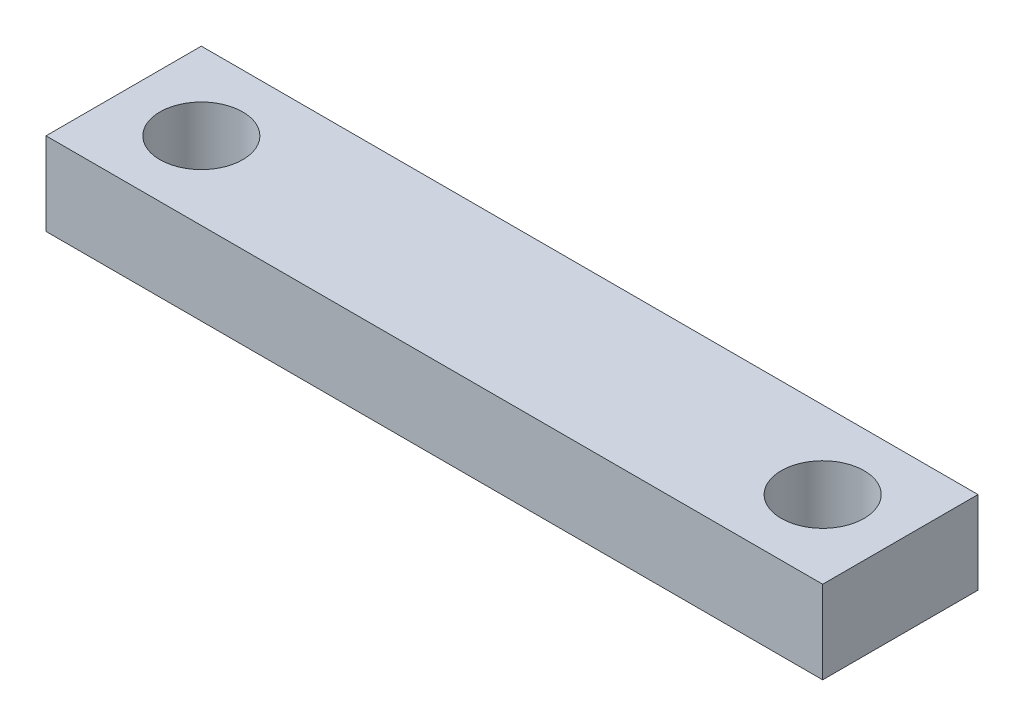
from build123d import *

# Parameters (mm, degrees)
BOSS_EXTRUDE1_DEPTH = 8


with BuildPart() as part:
    # Sketch2 → Boss-Extrude1 (new body)
    with BuildSketch(Plane(origin=(0, 0, 0), x_dir=(1, 0, 0), z_dir=(0, 1, 0))):
        with BuildLine():
            ThreePointArc((26, 0), (30, 4), (34, 0))
            Line((34, 0), (37.5, 0))
            Line((37.5, 0), (37.5, 7.5))
            Line((37.5, 7.5), (-37.5, 7.5))
            Line((-37.5, 7.5), (-37.5, 0))
            Line((-37.5, 0), (-34, 0))
            ThreePointArc((-34, 0), (-30, 4), (-26, 0))
            Line((-26, 0), (26, 0))
        make_face()
        with BuildLine():
            Line((37.5, 0), (34, 0))
            ThreePointArc((34, 0), (30, -4), (26, 0))
            Line((26, 0), (-26, 0))
            ThreePointArc((-26, 0), (-30, -4), (-34, 0))
            Line((-34, 0), (-37.5, 0))
            Line((-37.5, 0), (-37.5, -7.5))
            Line((-37.5, -7.5), (37.5, -7.5))
            Line((37.5, -7.5), (37.5, 0))
        make_face()
    extrude(amount=BOSS_EXTRUDE1_DEPTH)


solid = part.part
